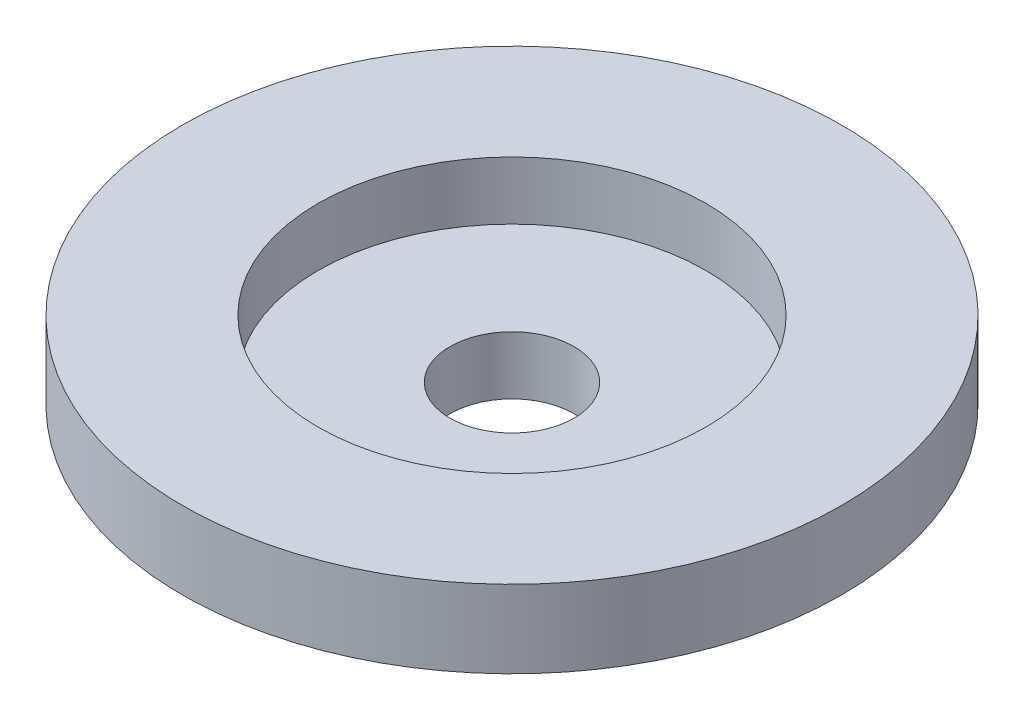
from build123d import *


with BuildPart() as part:
    # Sketch1 → Revolve1 (revolve)
    with BuildSketch(Plane.XY):
        Polygon((-1.6, 0), (-6.5, 0), (-6.5, 1), (-8.5, 1), (-8.5, 3), (-5, 3), (-5, 1.5), (-1.6, 1.5), align=None)
    revolve(axis=Axis((0, -1000, 0), (0, 1, 0)))


solid = part.part
